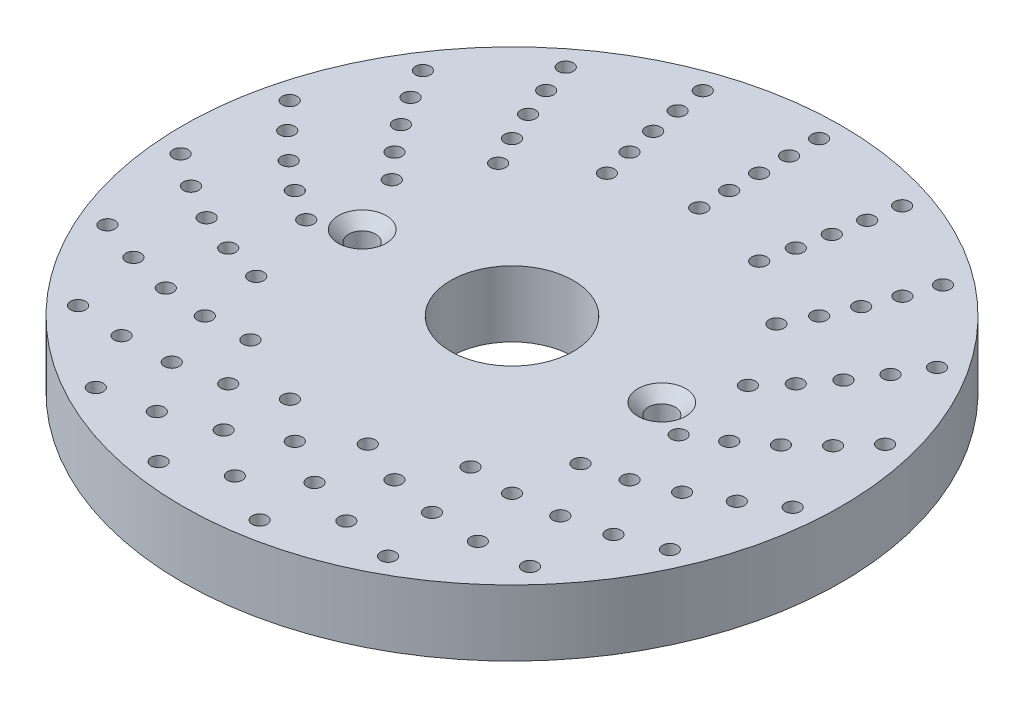
from build123d import *

# Parameters (mm, degrees)
CROQUIS1_R              = 55
SALIENTE_EXTRUIR1_DEPTH = 5.5
CROQUIS3_R              = 1.25
CORTAR_EXTRUIR1_DEPTH   = 3.5
MATRIZC1_COUNT          = 15
CROQUIS4_R              = 1.25
CORTAR_EXTRUIR2_DEPTH   = 3.5
MATRIZC2_COUNT          = 16
CROQUIS6_R              = 1.25
CORTAR_EXTRUIR4_DEPTH   = 3.5
MATRIZC3_COUNT          = 17
CROQUIS7_R              = 1.25
CORTAR_EXTRUIR5_DEPTH   = 3.5
MATRIZC4_COUNT          = 18
CROQUIS8_R              = 1.25
CORTAR_EXTRUIR6_DEPTH   = 3.5
MATRIZC5_COUNT          = 19
CROQUIS9_R              = 10.25
CORTAR_EXTRUIR7_DEPTH   = 36.3
CROQUIS10_R             = 1.25
CORTAR_EXTRUIR8_DEPTH   = 3.5
MATRIZC6_COUNT          = 20
CROQUIS11_R             = 1.25
CORTAR_EXTRUIR9_DEPTH   = 3.5
MATRIZC7_COUNT          = 21
CROQUIS12_R             = 1.25
CORTAR_EXTRUIR10_DEPTH  = 3.5
MATRIZC8_COUNT          = 23
CROQUIS13_R             = 1.25
CORTAR_EXTRUIR11_DEPTH  = 3.5
MATRIZC9_COUNT          = 27
CROQUIS14_R             = 1.25
CORTAR_EXTRUIR12_DEPTH  = 3.5
MATRIZC10_COUNT         = 29


with BuildPart() as part:
    # Croquis1 → Saliente-Extruir1 (new body, symmetric)
    with BuildSketch(Plane(origin=(0, 0, 0), x_dir=(1, 0, 0), z_dir=(0, 1, 0))):
        Circle(CROQUIS1_R)
    extrude(amount=SALIENTE_EXTRUIR1_DEPTH, both=True)

    # Croquis2 → Cortar-Revolución1 (revolve, cut)
    with BuildSketch(Plane.XY):
        Polygon((-25, 5.5), (-29, 5.5), (-27.25, 3.7), (-27.25, -3.7), (-29, -5.5), (-25, -5.5), align=None)
    cortar_revoluci_n1 = revolve(axis=Axis((-25, 24.94194593, 0), (0, -1, 0)), mode=Mode.SUBTRACT)

    # Simetría1: Cortar-Revolución1 across plane
    add(cortar_revoluci_n1.mirror(Plane(origin=(0, 0, 0), x_dir=(0, 0, 1), z_dir=(1, 0, 0))), mode=Mode.SUBTRACT)

    # Croquis3 → Cortar-Extruir1 (cut)
    with BuildSketch(Plane(origin=(0, 5.5, 0), x_dir=(1, 0, 0), z_dir=(0, 1, 0))):
        with Locations((0, 31.25)):
            Circle(CROQUIS3_R)
    cortar_extruir1 = extrude(amount=-CORTAR_EXTRUIR1_DEPTH, mode=Mode.SUBTRACT)

    # MatrizC1: Cortar-Extruir1 ×15 about axis
    matrizc1_axis = Axis((0, 0, 0), (0, 1, 0))
    for i in range(1, MATRIZC1_COUNT):
        add(cortar_extruir1.rotate(matrizc1_axis, i * 360 / MATRIZC1_COUNT), mode=Mode.SUBTRACT)

    # Croquis4 → Cortar-Extruir2 (cut)
    with BuildSketch(Plane(origin=(0, 5.5, 0), x_dir=(1, 0, 0), z_dir=(0, 1, 0))):
        with Locations((0, 36.25)):
            Circle(CROQUIS4_R)
    cortar_extruir2 = extrude(amount=-CORTAR_EXTRUIR2_DEPTH, mode=Mode.SUBTRACT)

    # MatrizC2: Cortar-Extruir2 ×16 about axis
    matrizc2_axis = Axis((0, 0, 0), (0, 1, 0))
    for i in range(1, MATRIZC2_COUNT):
        add(cortar_extruir2.rotate(matrizc2_axis, i * 360 / MATRIZC2_COUNT), mode=Mode.SUBTRACT)

    # Croquis6 → Cortar-Extruir4 (cut)
    with BuildSketch(Plane(origin=(0, 5.5, 0), x_dir=(1, 0, 0), z_dir=(0, 1, 0))):
        with Locations((0, 41.25)):
            Circle(CROQUIS6_R)
    cortar_extruir4 = extrude(amount=-CORTAR_EXTRUIR4_DEPTH, mode=Mode.SUBTRACT)

    # MatrizC3: Cortar-Extruir4 ×17 about axis
    matrizc3_axis = Axis((0, 0, 0), (0, 1, 0))
    for i in range(1, MATRIZC3_COUNT):
        add(cortar_extruir4.rotate(matrizc3_axis, i * 360 / MATRIZC3_COUNT), mode=Mode.SUBTRACT)

    # Croquis7 → Cortar-Extruir5 (cut)
    with BuildSketch(Plane(origin=(0, 5.5, 0), x_dir=(1, 0, 0), z_dir=(0, 1, 0))):
        with Locations((0, 46.25)):
            Circle(CROQUIS7_R)
    cortar_extruir5 = extrude(amount=-CORTAR_EXTRUIR5_DEPTH, mode=Mode.SUBTRACT)

    # MatrizC4: Cortar-Extruir5 ×18 about axis
    matrizc4_axis = Axis((0, 0, 0), (0, 1, 0))
    for i in range(1, MATRIZC4_COUNT):
        add(cortar_extruir5.rotate(matrizc4_axis, i * 360 / MATRIZC4_COUNT), mode=Mode.SUBTRACT)

    # Croquis8 → Cortar-Extruir6 (cut)
    with BuildSketch(Plane(origin=(0, 5.5, 0), x_dir=(1, 0, 0), z_dir=(0, 1, 0))):
        with Locations((0, 51.25)):
            Circle(CROQUIS8_R)
    cortar_extruir6 = extrude(amount=-CORTAR_EXTRUIR6_DEPTH, mode=Mode.SUBTRACT)

    # MatrizC5: Cortar-Extruir6 ×19 about axis
    matrizc5_axis = Axis((0, 0, 0), (0, 1, 0))
    for i in range(1, MATRIZC5_COUNT):
        add(cortar_extruir6.rotate(matrizc5_axis, i * 360 / MATRIZC5_COUNT), mode=Mode.SUBTRACT)

    # Croquis9 → Cortar-Extruir7 (cut)
    with BuildSketch(Plane(origin=(0, 5.5, 0), x_dir=(1, 0, 0), z_dir=(0, 1, 0))):
        Circle(CROQUIS9_R)
    extrude(amount=-CORTAR_EXTRUIR7_DEPTH, mode=Mode.SUBTRACT)

    # Croquis10 → Cortar-Extruir8 (cut)
    with BuildSketch(Plane.XZ.offset(5.5)):
        with Locations((0, -31.25)):
            Circle(CROQUIS10_R)
    cortar_extruir8 = extrude(amount=-CORTAR_EXTRUIR8_DEPTH, mode=Mode.SUBTRACT)

    # MatrizC6: Cortar-Extruir8 ×20 about axis
    matrizc6_axis = Axis((0, 0, 0), (0, 1, 0))
    for i in range(1, MATRIZC6_COUNT):
        add(cortar_extruir8.rotate(matrizc6_axis, i * 360 / MATRIZC6_COUNT), mode=Mode.SUBTRACT)

    # Croquis11 → Cortar-Extruir9 (cut)
    with BuildSketch(Plane.XZ.offset(5.5)):
        with Locations((0, -36.25)):
            Circle(CROQUIS11_R)
    cortar_extruir9 = extrude(amount=-CORTAR_EXTRUIR9_DEPTH, mode=Mode.SUBTRACT)

    # MatrizC7: Cortar-Extruir9 ×21 about axis
    matrizc7_axis = Axis((0, 0, 0), (0, 1, 0))
    for i in range(1, MATRIZC7_COUNT):
        add(cortar_extruir9.rotate(matrizc7_axis, i * 360 / MATRIZC7_COUNT), mode=Mode.SUBTRACT)

    # Croquis12 → Cortar-Extruir10 (cut)
    with BuildSketch(Plane.XZ.offset(5.5)):
        with Locations((0, -41.25)):
            Circle(CROQUIS12_R)
    cortar_extruir10 = extrude(amount=-CORTAR_EXTRUIR10_DEPTH, mode=Mode.SUBTRACT)

    # MatrizC8: Cortar-Extruir10 ×23 about axis
    matrizc8_axis = Axis((0, 0, 0), (0, 1, 0))
    for i in range(1, MATRIZC8_COUNT):
        add(cortar_extruir10.rotate(matrizc8_axis, i * 360 / MATRIZC8_COUNT), mode=Mode.SUBTRACT)

    # Croquis13 → Cortar-Extruir11 (cut)
    with BuildSketch(Plane.XZ.offset(5.5)):
        with Locations((0, -46.25)):
            Circle(CROQUIS13_R)
    cortar_extruir11 = extrude(amount=-CORTAR_EXTRUIR11_DEPTH, mode=Mode.SUBTRACT)

    # MatrizC9: Cortar-Extruir11 ×27 about axis
    matrizc9_axis = Axis((0, 0, 0), (0, 1, 0))
    for i in range(1, MATRIZC9_COUNT):
        add(cortar_extruir11.rotate(matrizc9_axis, i * 360 / MATRIZC9_COUNT), mode=Mode.SUBTRACT)

    # Croquis14 → Cortar-Extruir12 (cut)
    with BuildSketch(Plane.XZ.offset(5.5)):
        with Locations((0, -51.25)):
            Circle(CROQUIS14_R)
    cortar_extruir12 = extrude(amount=-CORTAR_EXTRUIR12_DEPTH, mode=Mode.SUBTRACT)

    # MatrizC10: Cortar-Extruir12 ×29 about axis
    matrizc10_axis = Axis((0, 0, 0), (0, 1, 0))
    for i in range(1, MATRIZC10_COUNT):
        add(cortar_extruir12.rotate(matrizc10_axis, i * 360 / MATRIZC10_COUNT), mode=Mode.SUBTRACT)


solid = part.part
